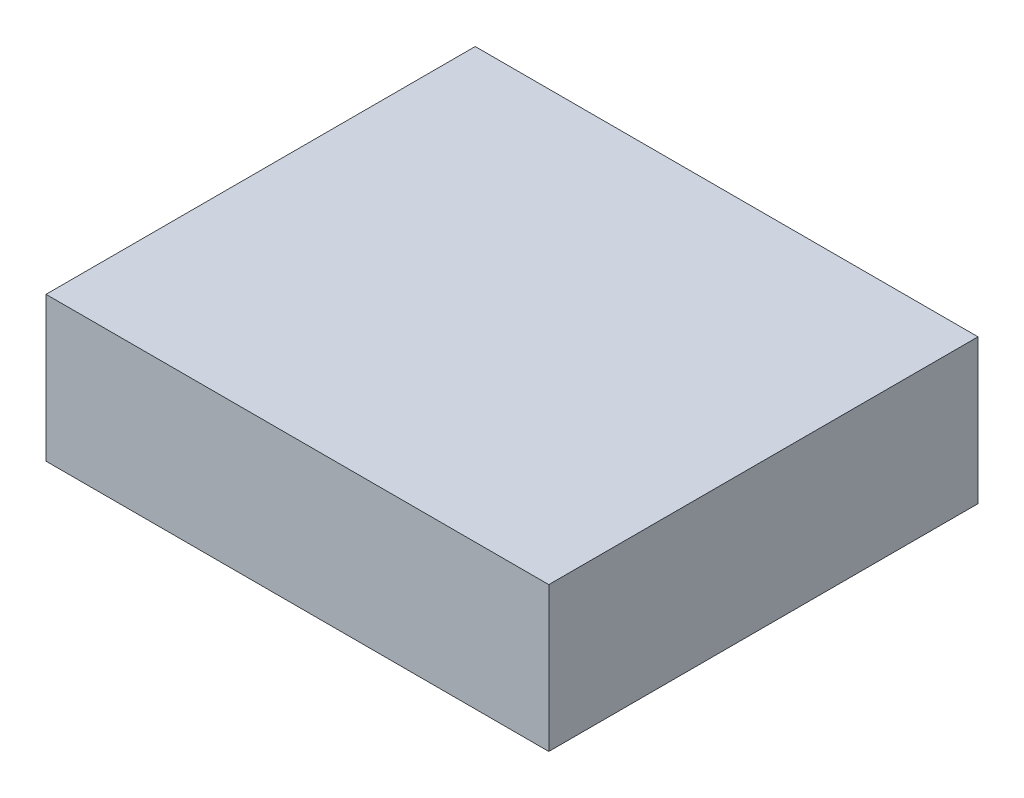
from build123d import *

# Parameters (mm, degrees)
SKETCH1_W           = 57.4
SKETCH1_H           = 49
BOSS_EXTRUDE1_DEPTH = 16.5


with BuildPart() as part:
    # Sketch1 → Boss-Extrude1 (new body)
    with BuildSketch(Plane(origin=(0, 0, 0), x_dir=(1, 0, 0), z_dir=(0, 1, 0))):
        Rectangle(SKETCH1_W, SKETCH1_H)
    extrude(amount=BOSS_EXTRUDE1_DEPTH)


solid = part.part
